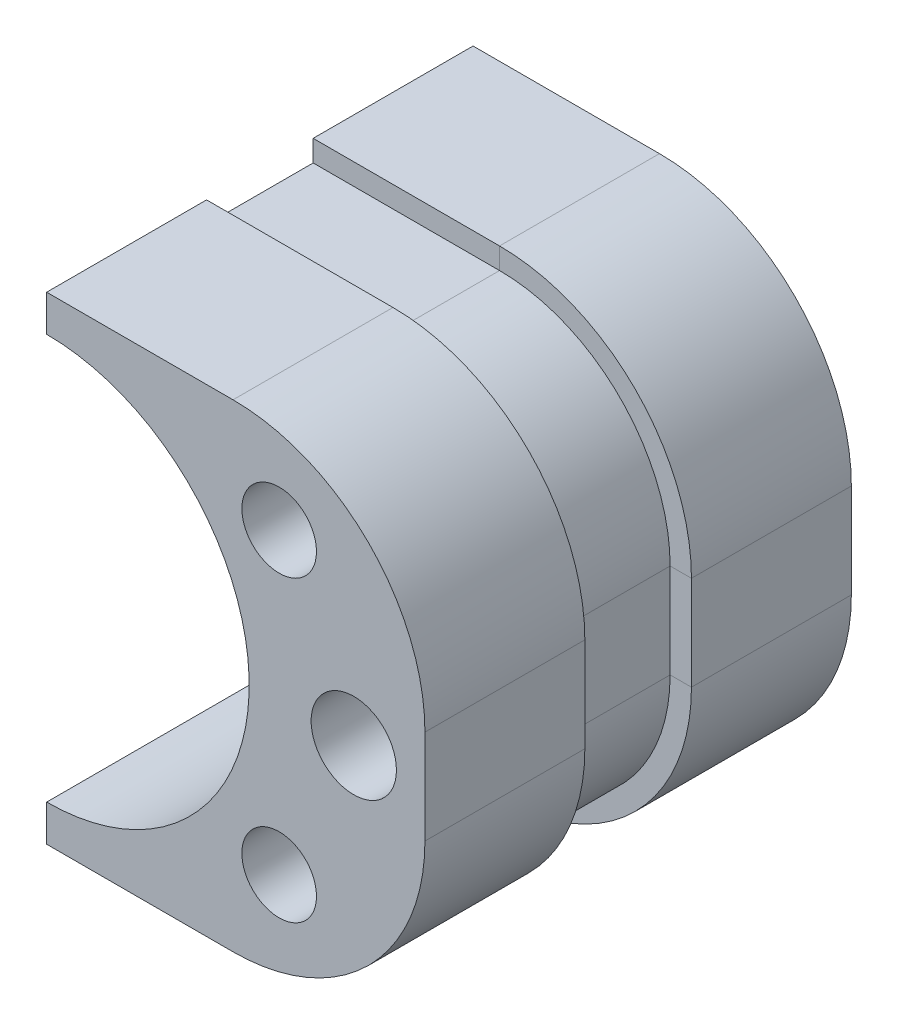
from build123d import *

# Parameters (mm, degrees)
ESBO_O1_R                = 1.393053459
ESBO_O1_R_2              = 4
RESSALTO_EXTRUS_O1_DEPTH = 40
ESBO_O8_W                = 10
ESBO_O8_H                = 2
ESBO_O10_R               = 3.5
CORTE_EXTRUS_O1_DEPTH    = 10


with BuildPart() as part:
    # Esboço1 → Ressalto-extrusão1 (new body)
    with BuildSketch(Plane.XY):
        with BuildLine():
            Line((0.112562331, -22.423877672), (0.112562331, -19))
            ThreePointArc((0.112562331, -19), (19.112562331, 0), (0.112562331, 19))
            Line((0.112562331, 19), (0.112562331, 22.423877672))
            Line((0.112562331, 22.423877672), (17.598208573, 22.423877672))
            ThreePointArc((17.598208573, 22.423877672), (30.326130634, 17.151799733), (35.598208573, 4.423877672))
            Line((35.598208573, 4.423877672), (35.598208573, -4.423877672))
            ThreePointArc((35.598208573, -4.423877672), (30.326130634, -17.151799733), (17.598208573, -22.423877672))
            Line((17.598208573, -22.423877672), (0.112562331, -22.423877672))
        make_face()
        with Locations((21.9231968, -14)):
            Circle(ESBO_O1_R, mode=Mode.SUBTRACT)
        with Locations((21.9231968, 14)):
            Circle(ESBO_O1_R, mode=Mode.SUBTRACT)
        with Locations((28.9231968, 0)):
            Circle(ESBO_O1_R_2, mode=Mode.SUBTRACT)
    extrude(amount=RESSALTO_EXTRUS_O1_DEPTH)

    # Varredura de corte1: sweep along a path in Esboço9
    with BuildLine(Plane.XY.offset(40)) as varredura_de_corte1_path:
        Line((0.112562331, -22.423877672), (17.598208573, -22.423877672))
        ThreePointArc((17.598208573, -22.423877672), (30.326130634, -17.151799733), (35.598208573, -4.423877672))
        Line((35.598208573, -4.423877672), (35.598208573, 4.423877672))
        ThreePointArc((35.598208573, 4.423877672), (30.326130634, 17.151799733), (17.598208573, 22.423877672))
        Line((17.598208573, 22.423877672), (0.112562331, 22.423877672))
    # Esboço8 → Varredura de corte1 (sweep, cut)
    with BuildSketch(Plane.ZY.offset(-0.112562331)):
        with Locations((20, 21.423877672)):
            Rectangle(ESBO_O8_W, ESBO_O8_H)
    sweep(path=varredura_de_corte1_path.line, mode=Mode.SUBTRACT)

    # Esboço10 → Corte-extrusão1 (cut)
    with BuildSketch(Plane.XY.offset(40)):
        with Locations((21.9231968, 14)):
            Circle(ESBO_O10_R)
        with Locations((21.9231968, -14)):
            Circle(ESBO_O10_R)
    extrude(amount=-CORTE_EXTRUS_O1_DEPTH, mode=Mode.SUBTRACT)


solid = part.part
